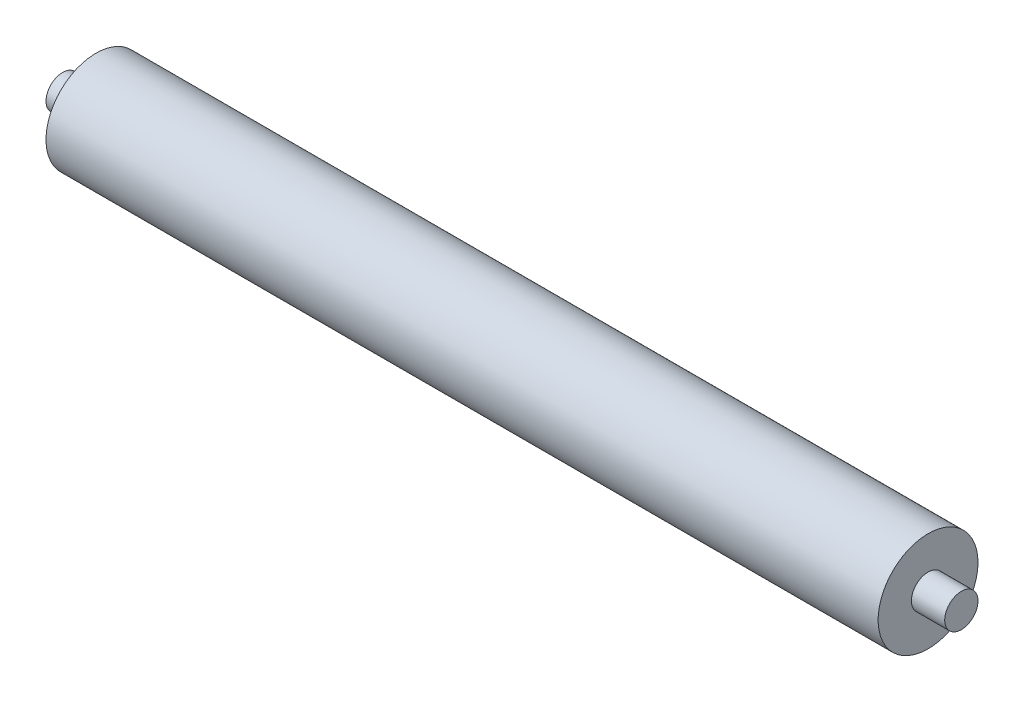
from build123d import *

# Parameters (mm, degrees)
CROQUIS1_R              = 1.5
SALIENTE_EXTRUIR1_DEPTH = 25
CROQUIS2_R              = 0.5
SALIENTE_EXTRUIR2_DEPTH = 1
CROQUIS3_R              = 0.5
SALIENTE_EXTRUIR3_DEPTH = 1


with BuildPart() as part:
    # Croquis1 → Saliente-Extruir1 (new body)
    with BuildSketch(Plane(origin=(0, 0, 0), x_dir=(0, 0, -1), z_dir=(1, 0, 0))):
        Circle(CROQUIS1_R)
    extrude(amount=SALIENTE_EXTRUIR1_DEPTH)

    # Croquis2 → Saliente-Extruir2 (add)
    with BuildSketch(Plane(origin=(25, 0, 0), x_dir=(0, 0, -1), z_dir=(1, 0, 0))):
        Circle(CROQUIS2_R)
    extrude(amount=SALIENTE_EXTRUIR2_DEPTH)

    # Croquis3 → Saliente-Extruir3 (add)
    with BuildSketch(Plane.ZY):
        Circle(CROQUIS3_R)
    extrude(amount=SALIENTE_EXTRUIR3_DEPTH)


solid = part.part
